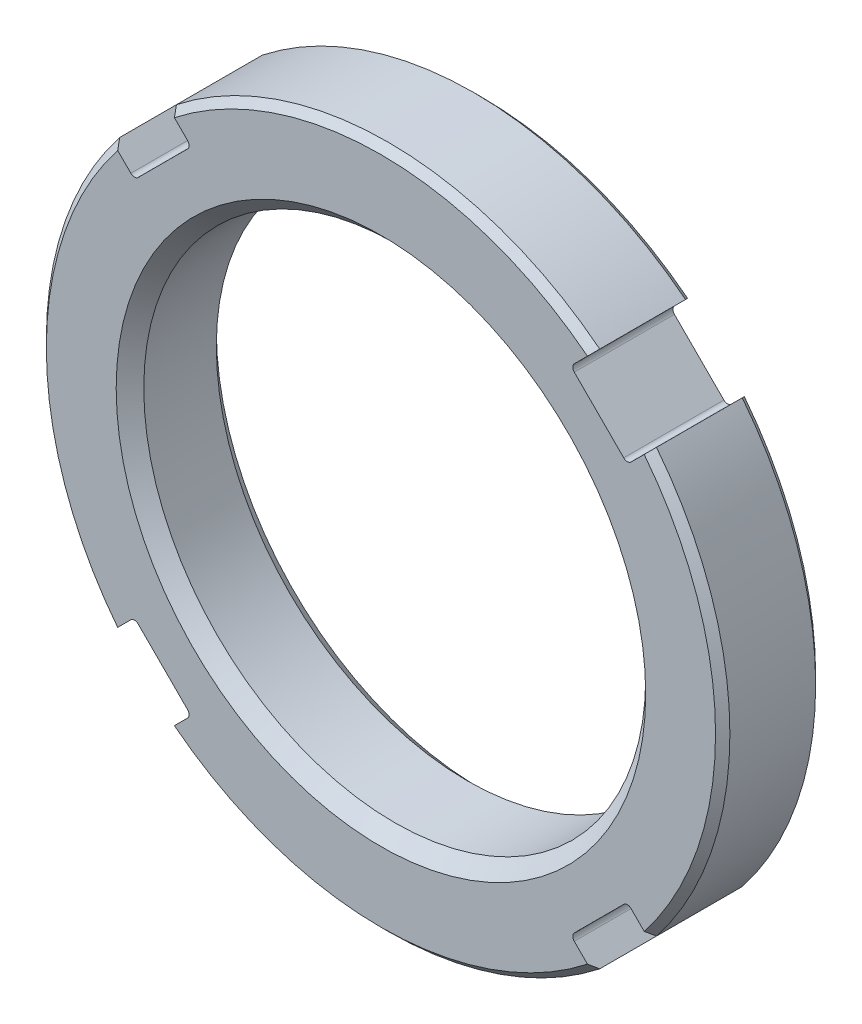
from build123d import *

# Parameters (mm, degrees)
SKETCH1_R                = 27.051
SKETCH1_R_2              = 19.8628
EXTRUDE1_DEPTH           = 7.9248
CHAMFER1_SIZE            = 0.567944
CHAMFER2_SIZE            = 1.0922
CUT_EXTRUDE1_DEPTH       = 8.9248
FILLET1_R                = 0.4064
CIRPATTERN1_COUNT        = 4
FILLET1_OF_CIRPATTERN1_R = 0.4064


with BuildPart() as part:
    # Sketch1 → Extrude1 (new body)
    with BuildSketch(Plane.XY):
        Circle(SKETCH1_R)
        Circle(SKETCH1_R_2, mode=Mode.SUBTRACT)
    extrude(amount=EXTRUDE1_DEPTH)

    # Chamfer1
    chamfer1_edges = [part.edges().sort_by_distance(p)[0] for p in [
        (-27.051, 0, 0),
        (-27.051, 0, 7.9248),
    ]]
    chamfer(chamfer1_edges, length=CHAMFER1_SIZE)

    # Chamfer2
    chamfer2_edges = [part.edges().sort_by_distance(p)[0] for p in [
        (-19.8628, 0, 0),
        (-19.8628, 0, 7.9248),
    ]]
    chamfer(chamfer2_edges, length=CHAMFER2_SIZE)

    # Sketch2 → Cut-Extrude1 (cut, through all)
    with BuildSketch(Plane.XY.offset(7.9248)):
        with BuildLine():
            Line((16.750672018, 21.240800078), (15.014988234, 19.505116295))
            Line((15.014988234, 19.505116295), (19.505116295, 15.014988234))
            Line((19.505116295, 15.014988234), (21.240800078, 16.750672018))
            ThreePointArc((21.240800078, 16.750672018), (19.127945538, 19.127945538), (16.750672018, 21.240800078))
        make_face()
    cut_extrude1 = extrude(amount=-CUT_EXTRUDE1_DEPTH, mode=Mode.SUBTRACT)

    # Fillet1
    fillet1_edges = [part.edges().sort_by_distance(p)[0] for p in [
        (19.505116295, 15.014988234, 3.9624),
        (15.014988234, 19.505116295, 3.9624),
    ]]
    fillet(fillet1_edges, radius=FILLET1_R)

    # CirPattern1: Cut-Extrude1 ×4 about axis
    cirpattern1_axis = Axis((0, 0, 0), (0, 0, 1))
    for i in range(1, CIRPATTERN1_COUNT):
        add(cut_extrude1.rotate(cirpattern1_axis, i * 360 / CIRPATTERN1_COUNT), mode=Mode.SUBTRACT)

    # Fillet1 of CirPattern1
    fillet1_of_cirpattern1_edges = [part.edges().sort_by_distance(p)[0] for p in [
        (-15.014988234, 19.505116295, 3.9624),
        (-19.505116295, 15.014988234, 3.9624),
        (-19.505116295, -15.014988234, 3.9624),
        (-15.014988234, -19.505116295, 3.9624),
        (15.014988234, -19.505116295, 3.9624),
        (19.505116295, -15.014988234, 3.9624),
    ]]
    fillet(fillet1_of_cirpattern1_edges, radius=FILLET1_OF_CIRPATTERN1_R)


solid = part.part
